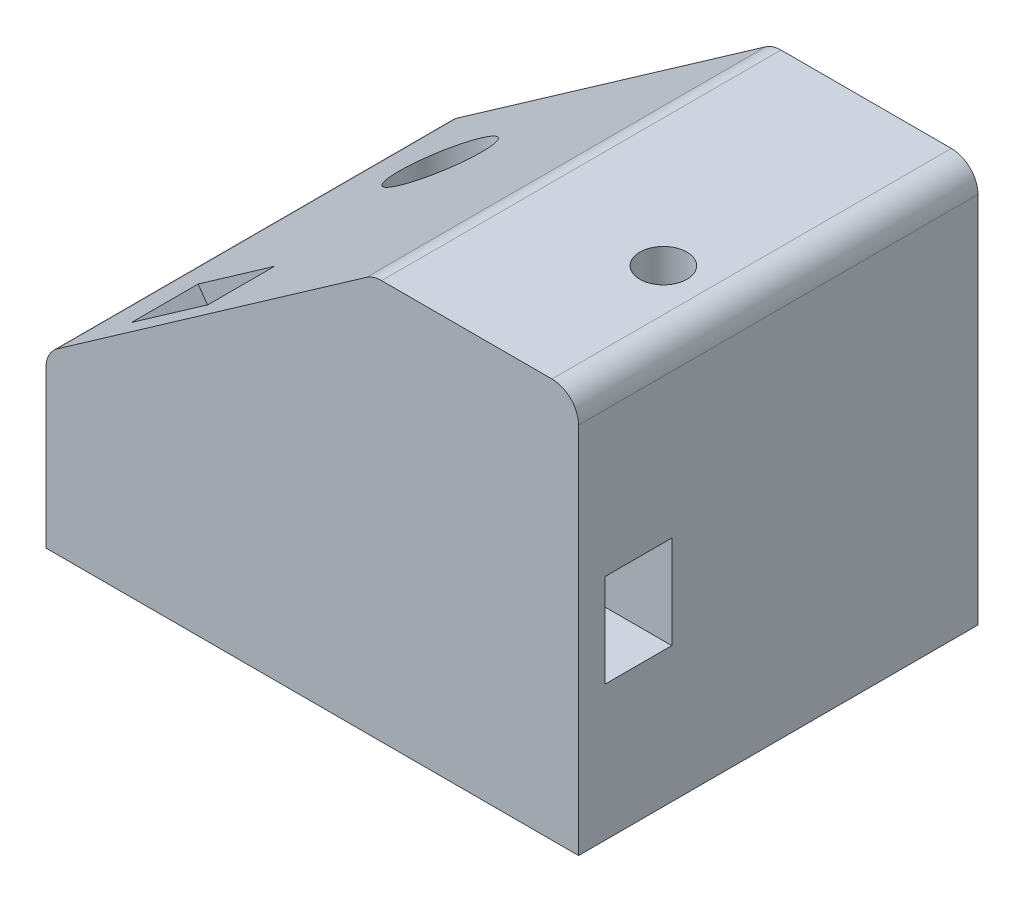
from build123d import *

# Parameters (mm, degrees)
BOSS_EXTRUDE1_DEPTH = 38.1
SKETCH4_W           = 8.89
SKETCH4_H           = 6.35
CUT_EXTRUDE1_DEPTH  = 8.89
SKETCH5_W           = 6.35
SKETCH5_H           = 8.89
CUT_EXTRUDE2_DEPTH  = 40.132
SKETCH6_R           = 2.2479
CUT_EXTRUDE3_DEPTH  = 74.93
CUT_EXTRUDE8_START  = -11.43
SKETCH10_R          = 3.937
CUT_EXTRUDE8_DEPTH  = 11.43


with BuildPart() as part:
    # Sketch1 → Boss-Extrude1 (new body)
    with BuildSketch(Plane.XY):
        with BuildLine():
            Line((0, 0), (50.8, 0))
            Line((50.8, 0), (50.8, 35.56))
            ThreePointArc((50.8, 35.56), (50.056051224, 37.356051224), (48.26, 38.1))
            Line((48.26, 38.1), (32.010551811, 38.1))
            ThreePointArc((32.010551811, 38.1), (31.24675908, 37.982441055), (30.553667663, 37.640646192))
            Line((30.553667663, 37.640646192), (1.083115852, 17.005143659))
            ThreePointArc((1.083115852, 17.005143659), (0.286992484, 16.097338944), (0, 14.924497467))
            Line((0, 14.924497467), (0, 0))
        make_face()
    extrude(amount=BOSS_EXTRUDE1_DEPTH)

    # Sketch4 → Cut-Extrude1 (cut)
    with BuildSketch(Plane(origin=(-7.6334698, 10.901724679, 0), x_dir=(0.819152044, 0.573576436, 0), z_dir=(-0.573576436, 0.819152044, 0))):
        with Locations((20.625340071, -32.385)):
            Rectangle(SKETCH4_W, SKETCH4_H)
    extrude(amount=-CUT_EXTRUDE1_DEPTH, mode=Mode.SUBTRACT)

    # Sketch5 → Cut-Extrude2 (cut)
    with BuildSketch(Plane(origin=(50.8, 0, 0), x_dir=(0, 0, -1), z_dir=(1, 0, 0))):
        with Locations((-32.385, 17.345124802)):
            Rectangle(SKETCH5_W, SKETCH5_H)
    extrude(amount=-CUT_EXTRUDE2_DEPTH, mode=Mode.SUBTRACT)

    # Sketch6 → Cut-Extrude3 (cut)
    with BuildSketch(Plane.XZ):
        with Locations((44.214054574, 23.424710834)):
            Circle(SKETCH6_R)
        with Locations((10.414, 10.922)):
            Circle(SKETCH6_R)
    extrude(amount=-CUT_EXTRUDE3_DEPTH, mode=Mode.SUBTRACT)

    # Sketch10 → Cut-Extrude8 (cut)
    with BuildSketch(Plane(origin=(0, 38.1, 0), x_dir=(1, 0, 0), z_dir=(0, 1, 0)).offset(CUT_EXTRUDE8_START)):
        with Locations((10.414, -10.922)):
            Circle(SKETCH10_R)
    extrude(amount=-CUT_EXTRUDE8_DEPTH, mode=Mode.SUBTRACT)


solid = part.part
